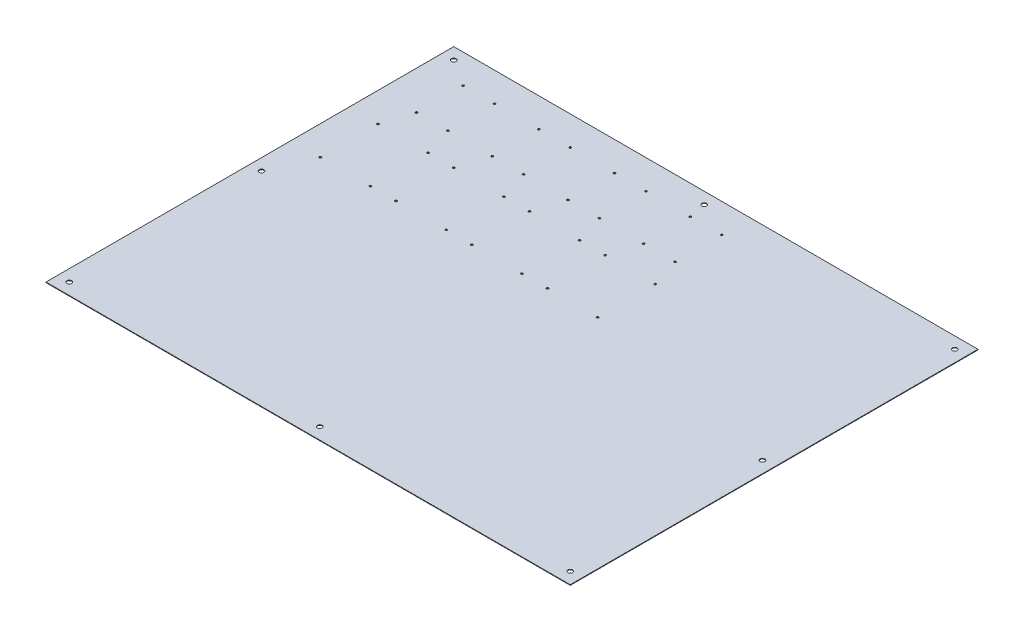
from build123d import *

# Parameters (mm, degrees)
SKETCH1_W           = 900
SKETCH1_H           = 700
SKETCH1_R           = 1.75
SKETCH1_R_2         = 4.1
BOSS_EXTRUDE1_DEPTH = 1


with BuildPart() as part:
    # Sketch1 → Boss-Extrude1 (new body)
    with BuildSketch(Plane(origin=(0, 0, 0), x_dir=(1, 0, 0), z_dir=(0, 1, 0))):
        with Locations((357, -170)):
            Rectangle(SKETCH1_W, SKETCH1_H)
        with Locations((-27, 130)):
            Circle(SKETCH1_R, mode=Mode.SUBTRACT)
        with Locations((27, 130)):
            Circle(SKETCH1_R, mode=Mode.SUBTRACT)
        with Locations((27, 50)):
            Circle(SKETCH1_R, mode=Mode.SUBTRACT)
        with Locations((-27, 50)):
            Circle(SKETCH1_R, mode=Mode.SUBTRACT)
        with Locations((-43, 0)):
            Circle(SKETCH1_R, mode=Mode.SUBTRACT)
        with Locations((43, 0)):
            Circle(SKETCH1_R, mode=Mode.SUBTRACT)
        with Locations((43, -99)):
            Circle(SKETCH1_R, mode=Mode.SUBTRACT)
        with Locations((-43, -99)):
            Circle(SKETCH1_R, mode=Mode.SUBTRACT)
        with Locations((103, 130)):
            Circle(SKETCH1_R, mode=Mode.SUBTRACT)
        with Locations((157, 130)):
            Circle(SKETCH1_R, mode=Mode.SUBTRACT)
        with Locations((157, 50)):
            Circle(SKETCH1_R, mode=Mode.SUBTRACT)
        with Locations((103, 50)):
            Circle(SKETCH1_R, mode=Mode.SUBTRACT)
        with Locations((87, 0)):
            Circle(SKETCH1_R, mode=Mode.SUBTRACT)
        with Locations((173, 0)):
            Circle(SKETCH1_R, mode=Mode.SUBTRACT)
        with Locations((173, -99)):
            Circle(SKETCH1_R, mode=Mode.SUBTRACT)
        with Locations((87, -99)):
            Circle(SKETCH1_R, mode=Mode.SUBTRACT)
        with Locations((233, 130)):
            Circle(SKETCH1_R, mode=Mode.SUBTRACT)
        with Locations((287, 130)):
            Circle(SKETCH1_R, mode=Mode.SUBTRACT)
        with Locations((287, 50)):
            Circle(SKETCH1_R, mode=Mode.SUBTRACT)
        with Locations((233, 50)):
            Circle(SKETCH1_R, mode=Mode.SUBTRACT)
        with Locations((217, 0)):
            Circle(SKETCH1_R, mode=Mode.SUBTRACT)
        with Locations((303, 0)):
            Circle(SKETCH1_R, mode=Mode.SUBTRACT)
        with Locations((303, -99)):
            Circle(SKETCH1_R, mode=Mode.SUBTRACT)
        with Locations((217, -99)):
            Circle(SKETCH1_R, mode=Mode.SUBTRACT)
        with Locations((363, 130)):
            Circle(SKETCH1_R, mode=Mode.SUBTRACT)
        with Locations((417, 130)):
            Circle(SKETCH1_R, mode=Mode.SUBTRACT)
        with Locations((417, 50)):
            Circle(SKETCH1_R, mode=Mode.SUBTRACT)
        with Locations((363, 50)):
            Circle(SKETCH1_R, mode=Mode.SUBTRACT)
        with Locations((347, 0)):
            Circle(SKETCH1_R, mode=Mode.SUBTRACT)
        with Locations((433, 0)):
            Circle(SKETCH1_R, mode=Mode.SUBTRACT)
        with Locations((433, -99)):
            Circle(SKETCH1_R, mode=Mode.SUBTRACT)
        with Locations((347, -99)):
            Circle(SKETCH1_R, mode=Mode.SUBTRACT)
        with Locations((-73, 160)):
            Circle(SKETCH1_R_2, mode=Mode.SUBTRACT)
        with Locations((787, 160)):
            Circle(SKETCH1_R_2, mode=Mode.SUBTRACT)
        with Locations((787, -500)):
            Circle(SKETCH1_R_2, mode=Mode.SUBTRACT)
        with Locations((-73, -500)):
            Circle(SKETCH1_R_2, mode=Mode.SUBTRACT)
        with Locations((-73, -170)):
            Circle(SKETCH1_R_2, mode=Mode.SUBTRACT)
        with Locations((357, 160)):
            Circle(SKETCH1_R_2, mode=Mode.SUBTRACT)
        with Locations((787, -170)):
            Circle(SKETCH1_R_2, mode=Mode.SUBTRACT)
        with Locations((357, -500)):
            Circle(SKETCH1_R_2, mode=Mode.SUBTRACT)
    extrude(amount=BOSS_EXTRUDE1_DEPTH)


solid = part.part
